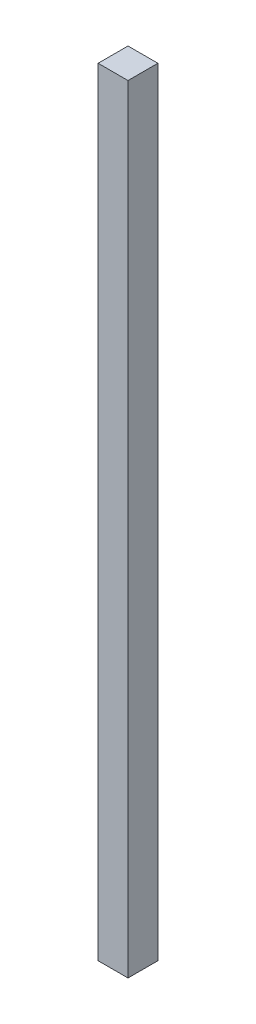
from build123d import *

# Parameters (mm, degrees)
SKETCH1_W           = 25.4
SKETCH1_H           = 25.4
BOSS_EXTRUDE1_DEPTH = 660.4


with BuildPart() as part:
    # Sketch1 → Boss-Extrude1 (new body)
    with BuildSketch(Plane(origin=(0, 0, 0), x_dir=(1, 0, 0), z_dir=(0, 1, 0))):
        with Locations((12.7, 12.7)):
            Rectangle(SKETCH1_W, SKETCH1_H)
    extrude(amount=BOSS_EXTRUDE1_DEPTH)


solid = part.part
